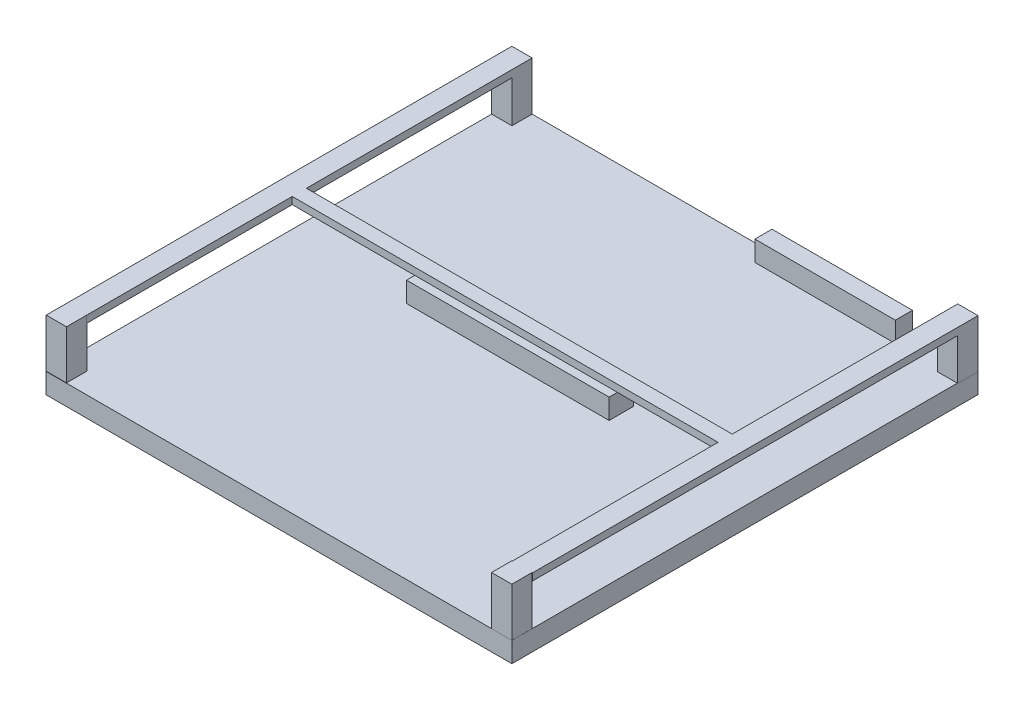
from build123d import *

# Parameters (mm, degrees)
SKETCH1_W            = 115
SKETCH1_H            = 115
BOSS_EXTRUDE3_DEPTH  = 5
SKETCH5_W            = 50
SKETCH5_H            = 6
SKETCH5_W_2          = 34.678216068
SKETCH5_H_2          = 4.225459606
BOSS_EXTRUDE4_DEPTH  = 5
SKETCH6_W            = 5
SKETCH6_H            = 5
BOSS_EXTRUDE5_DEPTH  = 12
SKETCH8_W            = 5
SKETCH8_H            = 1.75
BOSS_EXTRUDE7_DEPTH  = 105
SKETCH9_W            = 5
SKETCH9_H            = 1.75
BOSS_EXTRUDE8_DEPTH  = 105
SKETCH11_W           = 3.5
SKETCH11_H           = 1.75
BOSS_EXTRUDE10_DEPTH = 108


with BuildPart() as part:
    # Sketch1 → Boss-Extrude3 (new body)
    with BuildSketch(Plane(origin=(0, 0, 0), x_dir=(1, 0, 0), z_dir=(0, 1, 0))):
        Rectangle(SKETCH1_W, SKETCH1_H)
    extrude(amount=BOSS_EXTRUDE3_DEPTH)

    # Sketch5 → Boss-Extrude4 (add)
    with BuildSketch(Plane(origin=(0, 5, 0), x_dir=(1, 0, 0), z_dir=(0, 1, 0))):
        with Locations((-2.5, 4.5)):
            Rectangle(SKETCH5_W, SKETCH5_H)
        with Locations((24.044261594, 55.387270197)):
            Rectangle(SKETCH5_W_2, SKETCH5_H_2)
    extrude(amount=BOSS_EXTRUDE4_DEPTH)

    # Sketch6 → Boss-Extrude5 (add)
    with BuildSketch(Plane(origin=(0, 5, 0), x_dir=(1, 0, 0), z_dir=(0, 1, 0))):
        with Locations((-55.003212796, -54.936396199)):
            Rectangle(SKETCH6_W, SKETCH6_H)
        with Locations((-55, 55)):
            Rectangle(SKETCH6_W, SKETCH6_H)
        with Locations((55.107980821, 54.950828784)):
            Rectangle(SKETCH6_W, SKETCH6_H)
        with Locations((54.988780211, -55.003212796)):
            Rectangle(SKETCH6_W, SKETCH6_H)
    extrude(amount=BOSS_EXTRUDE5_DEPTH)

    # Sketch8 → Boss-Extrude7 (add)
    with BuildSketch(Plane.XY.offset(-52.5)):
        with Locations((-55, 16.125)):
            Rectangle(SKETCH8_W, SKETCH8_H)
    extrude(amount=BOSS_EXTRUDE7_DEPTH)

    # Sketch9 → Boss-Extrude8 (add)
    with BuildSketch(Plane.XY.offset(-52.450828784)):
        with Locations((55.107980821, 16.125)):
            Rectangle(SKETCH9_W, SKETCH9_H)
    extrude(amount=BOSS_EXTRUDE8_DEPTH)

    # Sketch11 → Boss-Extrude10 (add)
    with BuildSketch(Plane(origin=(-52.5, 0, 0), x_dir=(0, 0, -1), z_dir=(1, 0, 0))):
        with Locations((0.033603801, 16.125)):
            Rectangle(SKETCH11_W, SKETCH11_H)
    extrude(amount=BOSS_EXTRUDE10_DEPTH)


solid = part.part
